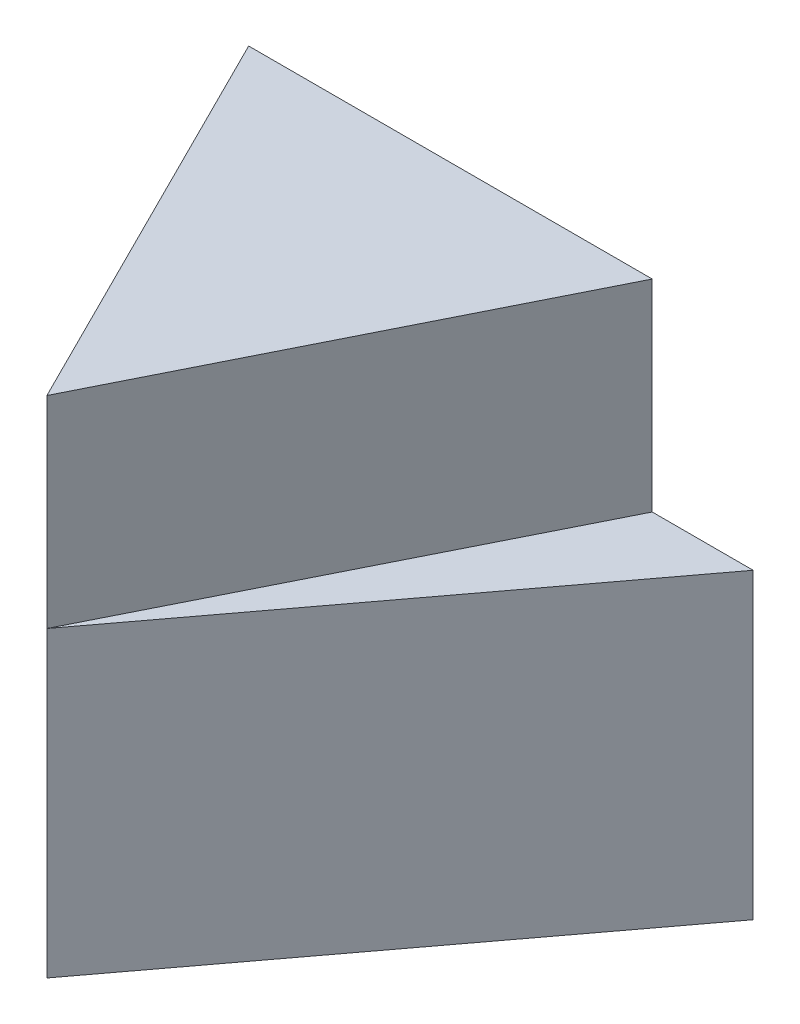
from build123d import *

# Parameters (mm, degrees)
BOSS_EXTRUDE1_DEPTH = 3
BOSS_EXTRUDE2_DEPTH = 2


with BuildPart() as part:
    # Sketch1 → Boss-Extrude1 (new body)
    with BuildSketch(Plane(origin=(0, 0, 0), x_dir=(1, 0, 0), z_dir=(0, 1, 0))):
        Polygon((0, 0), (-3, 4), (3, 4), align=None)
    extrude(amount=BOSS_EXTRUDE1_DEPTH)

    # Sketch2 → Boss-Extrude2 (add)
    with BuildSketch(Plane(origin=(0, 3, 0), x_dir=(1, 0, 0), z_dir=(0, 1, 0))):
        Polygon((0, 0), (-2, 4), (2, 4), align=None)
    extrude(amount=BOSS_EXTRUDE2_DEPTH)


solid = part.part
